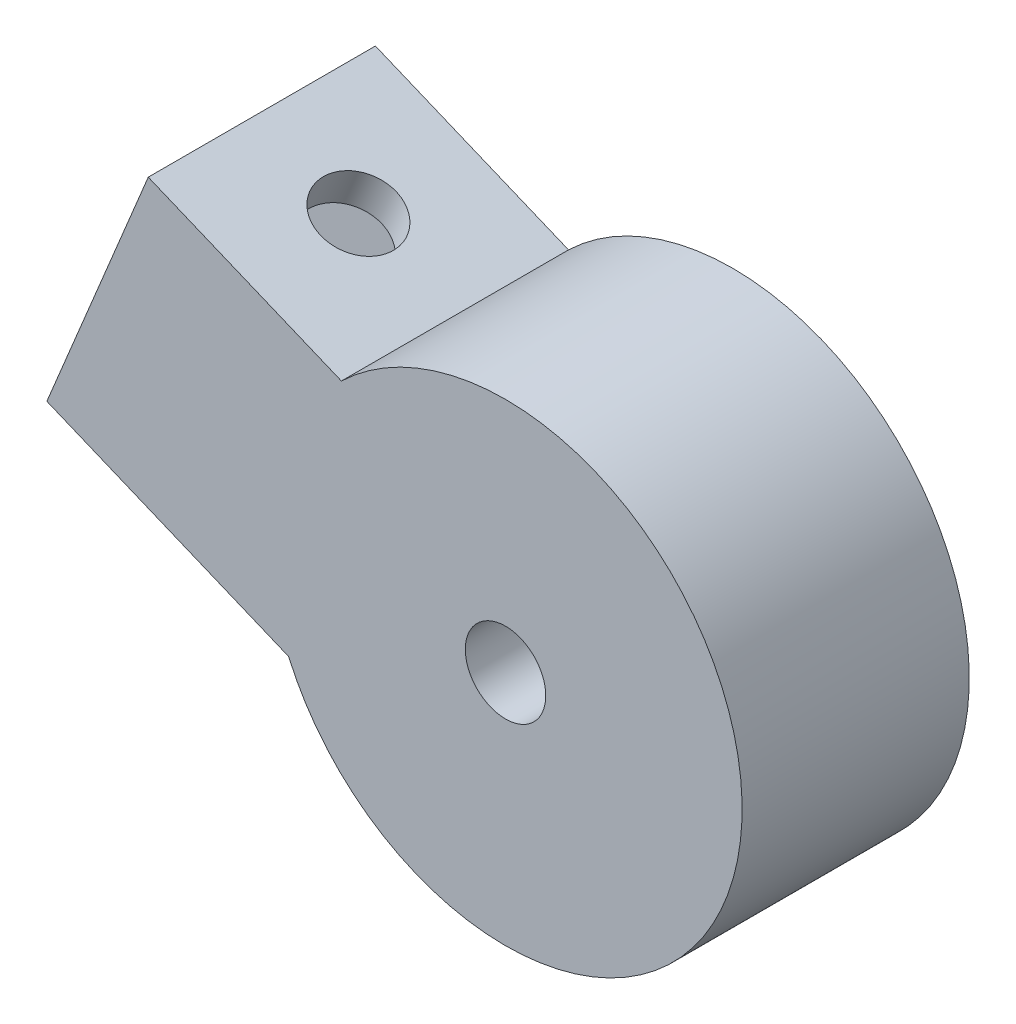
from build123d import *

# Parameters (mm, degrees)
SKETCH1_R           = 12.5
BOSS_EXTRUDE2_DEPTH = 12
BOSS_EXTRUDE3_DEPTH = 12
SKETCH3_W           = 8
SKETCH3_H           = 10
CUT_EXTRUDE1_DEPTH  = 10
SKETCH4_R           = 2
CUT_EXTRUDE2_DEPTH  = 14
SKETCH6_R           = 6.125
CUT_EXTRUDE3_DEPTH  = 4
SKETCH7_R           = 2.125
CUT_EXTRUDE4_DEPTH  = 9


with BuildPart() as part:
    # Sketch1 → Boss-Extrude2 (new body)
    with BuildSketch(Plane.XY):
        Circle(SKETCH1_R)
    extrude(amount=BOSS_EXTRUDE2_DEPTH)

    # Sketch2 → Boss-Extrude3 (add)
    with BuildSketch(Plane.XY):
        with BuildLine():
            Line((-24.231440373, 0.295461436), (-11.458506302, -4.995261088))
            ThreePointArc((-11.458506302, -4.995261088), (-12.259311424, 2.441164357), (-8.670952565, 9.003587153))
            Line((-8.670952565, 9.003587153), (-18.87387232, 13.229774891))
            Line((-18.87387232, 13.229774891), (-20.787289482, 8.610377228))
            Line((-20.787289482, 8.610377228), (-24.231440373, 0.295461436))
        make_face()
    extrude(amount=BOSS_EXTRUDE3_DEPTH)

    # Sketch3 → Cut-Extrude1 (cut)
    with BuildSketch(Plane(origin=(-20.787289482, 8.610377228, 0), x_dir=(0, 0, 1), z_dir=(-0.923879533, 0.382683432, 0))):
        with Locations((6, -2)):
            Rectangle(SKETCH3_W, SKETCH3_H)
    extrude(amount=-CUT_EXTRUDE1_DEPTH, mode=Mode.SUBTRACT)

    # Sketch4 → Cut-Extrude2 (cut)
    with BuildSketch(Plane(origin=(1.913417162, 4.619397663, 0), x_dir=(0.923879533, -0.382683432, 0), z_dir=(0.382683432, 0.923879533, 0))):
        with Locations((-16.978219619, -6)):
            Circle(SKETCH4_R)
    extrude(amount=-CUT_EXTRUDE2_DEPTH, mode=Mode.SUBTRACT)

    # Sketch6 → Cut-Extrude3 (cut)
    with BuildSketch(Plane(origin=(0, 0, 0), x_dir=(-1, 0, 0), z_dir=(0, 0, -1))):
        Circle(SKETCH6_R)
    extrude(amount=-CUT_EXTRUDE3_DEPTH, mode=Mode.SUBTRACT)

    # Sketch7 → Cut-Extrude4 (cut, through all)
    with BuildSketch(Plane(origin=(0, 0, 4), x_dir=(-1, 0, 0), z_dir=(0, 0, -1))):
        Circle(SKETCH7_R)
    extrude(amount=-CUT_EXTRUDE4_DEPTH, mode=Mode.SUBTRACT)


solid = part.part
